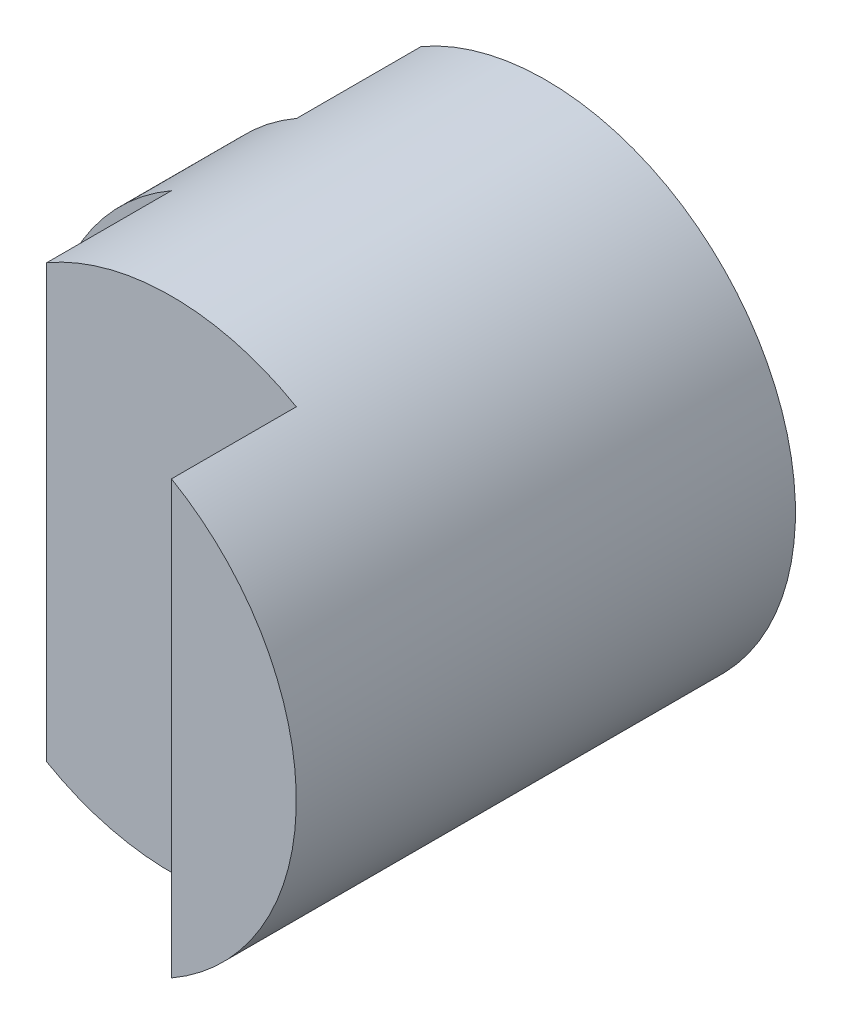
from build123d import *

# Parameters (mm, degrees)
SKETCH1_R           = 2
BOSS_EXTRUDE1_DEPTH = 4
SKETCH2_W           = 1
SKETCH2_H           = 0.996424707
CUT_EXTRUDE2_DEPTH  = 2


with BuildPart() as part:
    # Sketch1 → Boss-Extrude1 (new body)
    with BuildSketch(Plane.XY):
        Circle(SKETCH1_R)
    extrude(amount=BOSS_EXTRUDE1_DEPTH)

    # Sketch2 → Cut-Extrude2 (cut, symmetric)
    with BuildSketch(Plane(origin=(0, 0, 0), x_dir=(1, 0, 0), z_dir=(0, 1, 0))):
        Polygon((-1, -5), (1, -5), (1, -3), (-1, -3), (-1, -2), (-2, -2), (-2, -3), (-2, -5), align=None)
        with Locations((-1.5, -0.498212354)):
            Rectangle(SKETCH2_W, SKETCH2_H)
    extrude(amount=CUT_EXTRUDE2_DEPTH, both=True, mode=Mode.SUBTRACT)


solid = part.part
